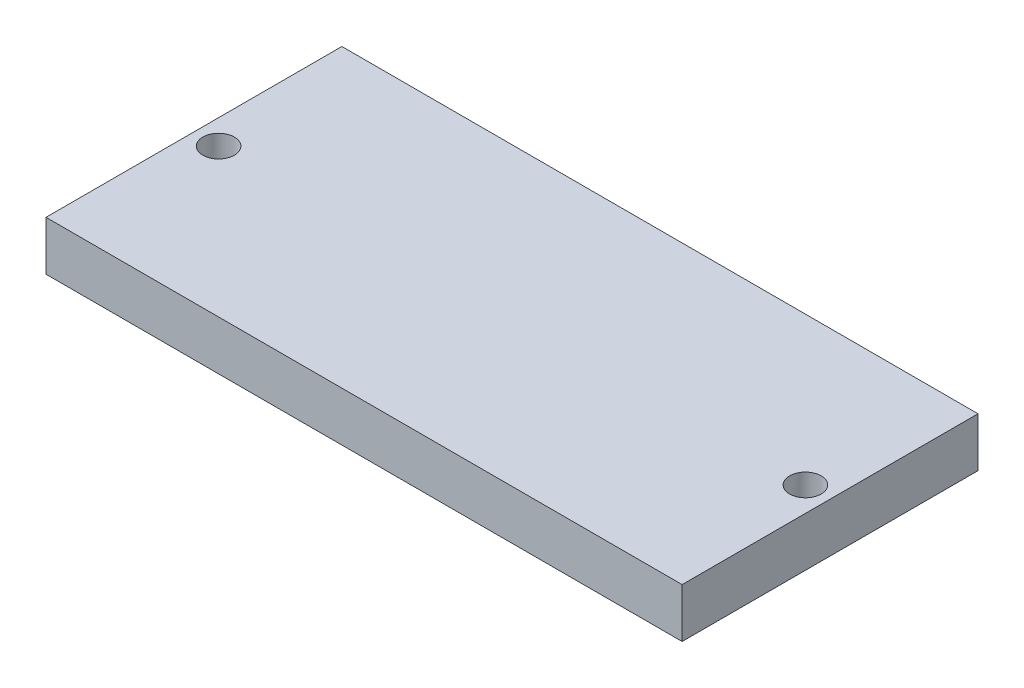
from build123d import *

# Parameters (mm, degrees)
CROQUIS1_W              = 64.5
CROQUIS1_H              = 30
SALIENTE_EXTRUIR1_DEPTH = 5
CROQUIS2_R              = 1.6
CORTAR_EXTRUIR1_DEPTH   = 6


with BuildPart() as part:
    # Croquis1 → Saliente-Extruir1 (new body)
    with BuildSketch(Plane(origin=(0, 0, 0), x_dir=(1, 0, 0), z_dir=(0, 1, 0))):
        Rectangle(CROQUIS1_W, CROQUIS1_H)
    extrude(amount=SALIENTE_EXTRUIR1_DEPTH)

    # Croquis2 → Cortar-Extruir1 (cut, through all)
    with BuildSketch(Plane(origin=(0, 5, 0), x_dir=(1, 0, 0), z_dir=(0, 1, 0))):
        with Locations((-29.75, 0)):
            Circle(CROQUIS2_R)
        with Locations((29.75, 0)):
            Circle(CROQUIS2_R)
    extrude(amount=-CORTAR_EXTRUIR1_DEPTH, mode=Mode.SUBTRACT)


solid = part.part
